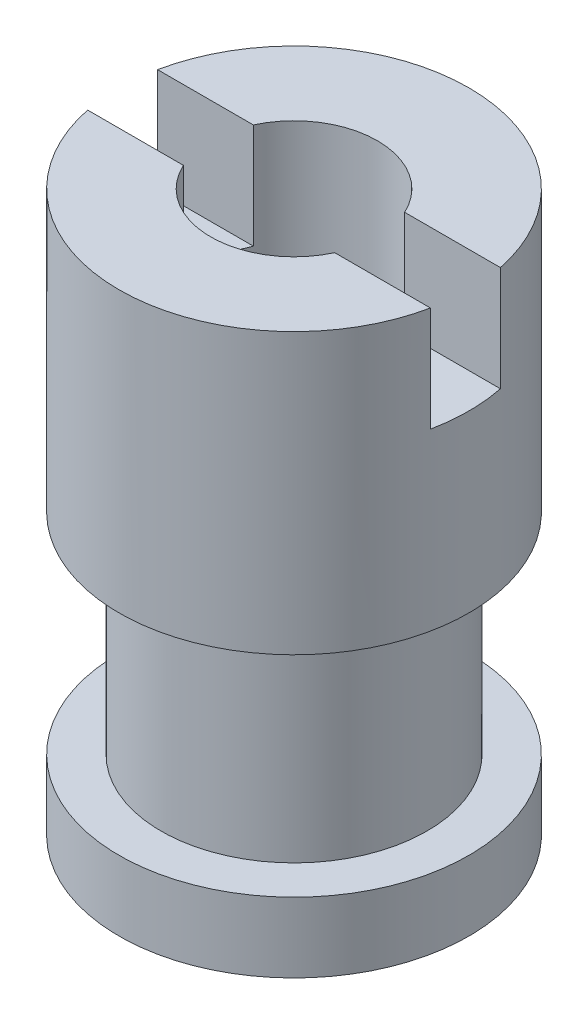
from build123d import *

# Parameters (mm, degrees)
CUT_EXTRUDE1_DEPTH = 0.75
SKETCH3_R          = 0.59563
CUT_EXTRUDE2_DEPTH = 5


with BuildPart() as part:
    # Sketch1 → Revolve1 (revolve)
    with BuildSketch(Plane.XY):
        Polygon((0, 0), (1.25, 0), (1.25, 0.5), (0.95, 0.5), (0.95, 2), (1.25, 2), (1.25, 4), (0, 4), align=None)
    revolve(axis=Axis((0, 0, 0), (0, 1, 0)))

    # Sketch2 → Cut-Extrude1 (cut)
    with BuildSketch(Plane(origin=(0, 4, 0), x_dir=(1, 0, 0), z_dir=(0, 1, 0))):
        Polygon((0, -0.25), (-1.5, -0.25), (-1.5, 0.25), (1.5, 0.25), (1.5, -0.25), align=None)
    extrude(amount=-CUT_EXTRUDE1_DEPTH, mode=Mode.SUBTRACT)

    # Sketch3 → Cut-Extrude2 (cut, through all)
    with BuildSketch(Plane.XZ):
        Circle(SKETCH3_R)
    extrude(amount=-CUT_EXTRUDE2_DEPTH, mode=Mode.SUBTRACT)


solid = part.part
